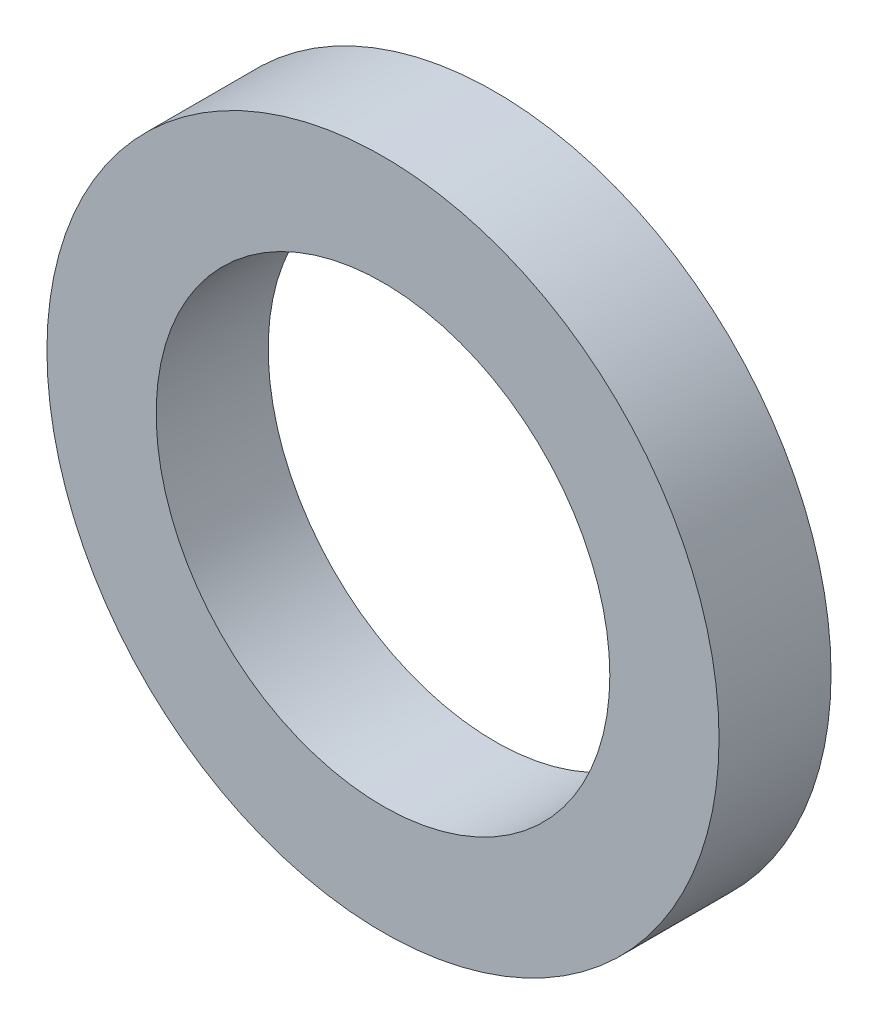
from build123d import *

# Parameters (mm, degrees)
SKETCH1_R           = 3
SKETCH1_R_2         = 2.025
BOSS_EXTRUDE1_DEPTH = 1


with BuildPart() as part:
    # Sketch1 → Boss-Extrude1 (new body)
    with BuildSketch(Plane.XY):
        Circle(SKETCH1_R)
        Circle(SKETCH1_R_2, mode=Mode.SUBTRACT)
    extrude(amount=BOSS_EXTRUDE1_DEPTH)


solid = part.part
